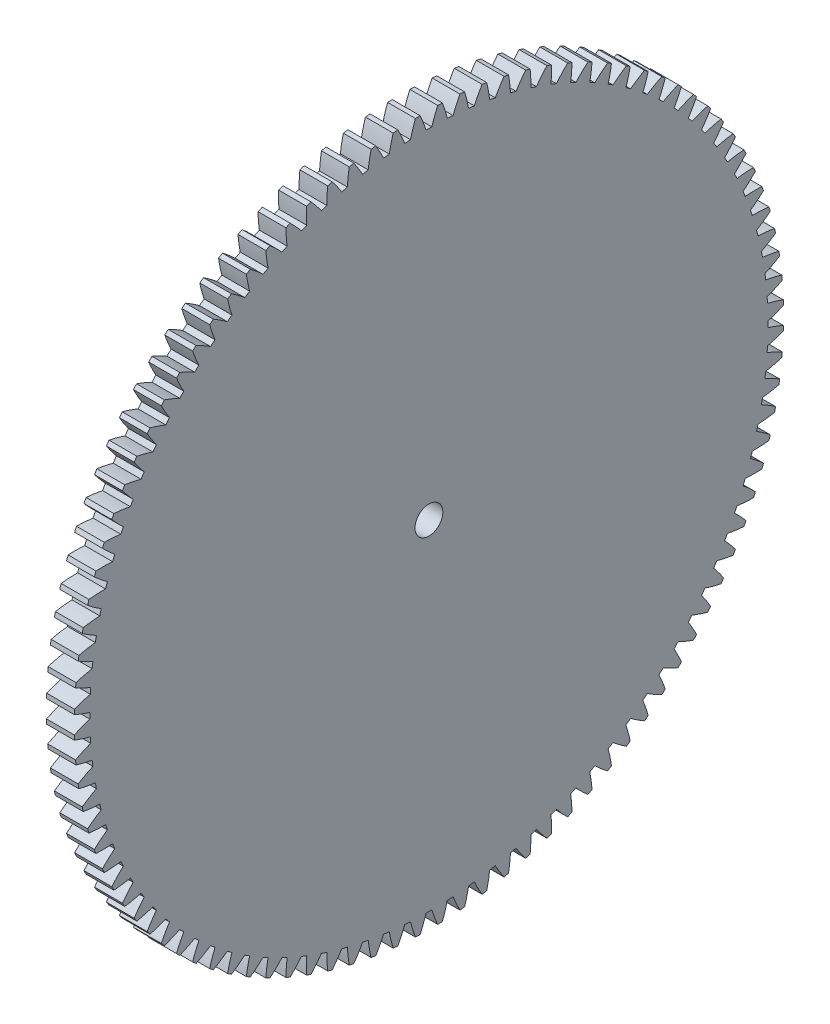
from build123d import *

# Parameters (mm, degrees)
BASPROSKE_W     = 4
BASPROSKE_H     = 51
TOOTHCUT_DEPTH  = 73.235725233
TEETHCUTS_COUNT = 100
TEETHCUTS_ANGLE = 356.4
BORSKE_R        = 2
BORE_DEPTH      = 50.0000508


with BuildPart() as part:
    # BasProSke → Base-Revolve (revolve)
    with BuildSketch(Plane(origin=(0, 0, 0), x_dir=(1, 0, 0), z_dir=(0, 1, 0)), mode=Mode.PRIVATE) as base_revolve_sk:
        with Locations((2, 25.5)):
            Rectangle(BASPROSKE_W, BASPROSKE_H)
    revolve(base_revolve_sk.sketch.rotate(Axis((-10, 0, 0), (1, 0, 0)), 180), axis=Axis((-10, 0, 0), (1, 0, 0)))

    # TooCutSke → ToothCut (cut, through all)
    with BuildSketch(Plane(origin=(0, 0, 0), x_dir=(0, 0, -1), z_dir=(1, 0, 0))):
        with BuildLine():
            ThreePointArc((0.414680742, 48.747236238), (0, 48.749), (-0.414680742, 48.747236238))
            ThreePointArc((-0.414680742, 48.747236238), (-0.812805308, 49.891397747), (-1.279472386, 51.009355961))
            ThreePointArc((-1.279472386, 51.009355961), (0, 51.0254), (1.279472386, 51.009355961))
            ThreePointArc((1.279472386, 51.009355961), (0.812805308, 49.891397747), (0.414680742, 48.747236238))
        make_face()
    toothcut = extrude(amount=TOOTHCUT_DEPTH, mode=Mode.SUBTRACT)

    # TeethCuts: ToothCut ×100 about axis
    teethcuts_axis = Axis((-10, 0, 0), (1, 0, 0))
    for i in range(1, TEETHCUTS_COUNT):
        add(toothcut.rotate(teethcuts_axis, i * TEETHCUTS_ANGLE / (TEETHCUTS_COUNT - 1)), mode=Mode.SUBTRACT)

    # BorSke → Bore (cut, symmetric)
    with BuildSketch(Plane(origin=(0, 0, 0), x_dir=(0, 0, -1), z_dir=(1, 0, 0))):
        with Locations(Location((0, 0, 0), (0, 0, 180))):
            Circle(BORSKE_R)
    extrude(amount=BORE_DEPTH, both=True, mode=Mode.SUBTRACT)


solid = part.part
